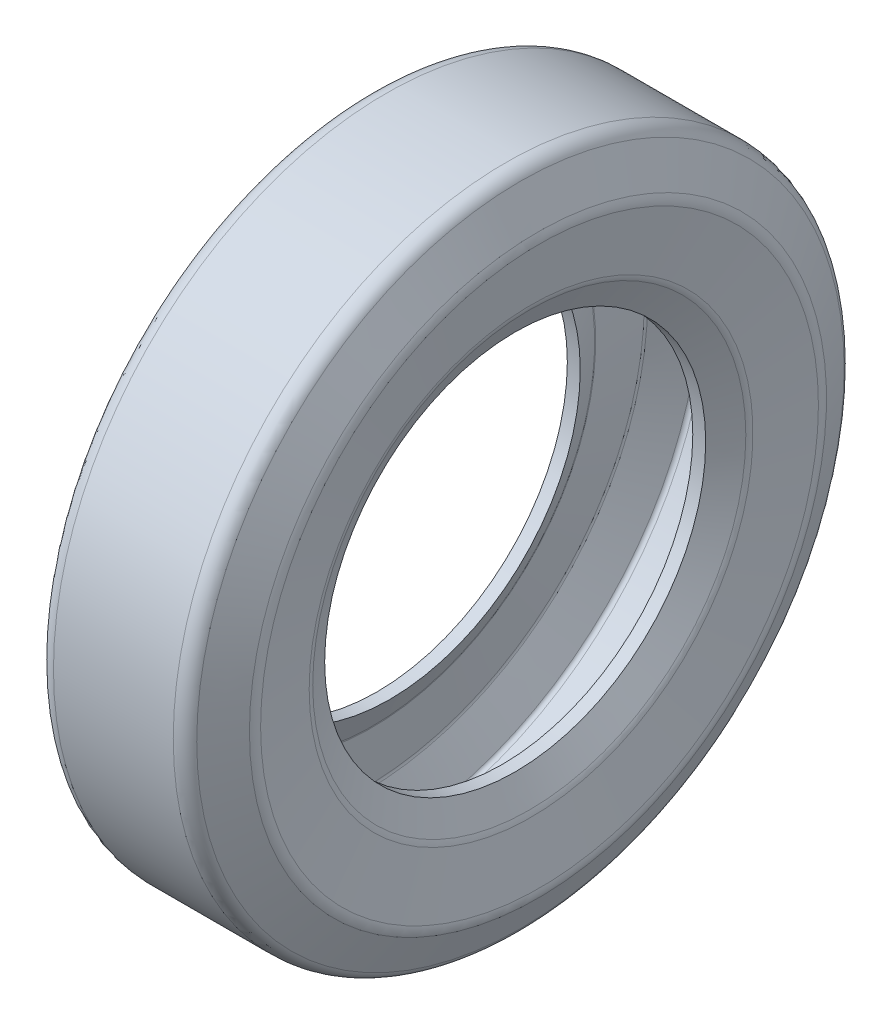
from build123d import *

# Parameters (mm, degrees)
SHELL1_T = -7


with BuildPart() as part:
    # Sketch1 → Revolve1 (revolve)
    with BuildSketch(Plane(origin=(0, 0, 0), x_dir=(1, 0, 0), z_dir=(0, 1, 0)), mode=Mode.PRIVATE) as revolve1_sk:
        with BuildLine():
            Line((-36.909830056, 205), (36.909830056, 205))
            ThreePointArc((36.909830056, 205), (42.167141177, 203.506508084), (45.854101966, 199.472135955))
            Line((45.854101966, 199.472135955), (56.680110893, 177.820118101))
            ThreePointArc((56.680110893, 177.820118101), (57.610939934, 174.923539576), (57.627669407, 171.881117848))
            Line((57.627669407, 171.881117848), (52.41719843, 136.744196592))
            ThreePointArc((52.41719843, 136.744196592), (52.012200987, 135.04878323), (51.318950924, 133.449454075))
            Line((51.318950924, 133.449454075), (42.635337046, 117.412834164))
            Line((42.635337046, 117.412834164), (-42.635337046, 117.412834164))
            Line((-42.635337046, 117.412834164), (-51.318950924, 133.449454075))
            ThreePointArc((-51.318950924, 133.449454075), (-52.012200987, 135.04878323), (-52.41719843, 136.744196592))
            Line((-52.41719843, 136.744196592), (-57.627669407, 171.881117848))
            ThreePointArc((-57.627669407, 171.881117848), (-57.610939934, 174.923539576), (-56.680110893, 177.820118101))
            Line((-56.680110893, 177.820118101), (-45.854101966, 199.472135955))
            ThreePointArc((-45.854101966, 199.472135955), (-42.167141177, 203.506508084), (-36.909830056, 205))
        make_face()
    revolve(revolve1_sk.sketch.rotate(Axis((-234.496124031, 0, 0), (1, 0, 0)), 180), axis=Axis((-234.496124031, 0, 0), (1, 0, 0)))

    # Shell1
    shell1_openings = [part.faces().sort_by_distance(p)[0] for p in [
        (0, 0, -117.412834164),
    ]]
    offset(amount=SHELL1_T, openings=shell1_openings, kind=Kind.INTERSECTION)


solid = part.part
